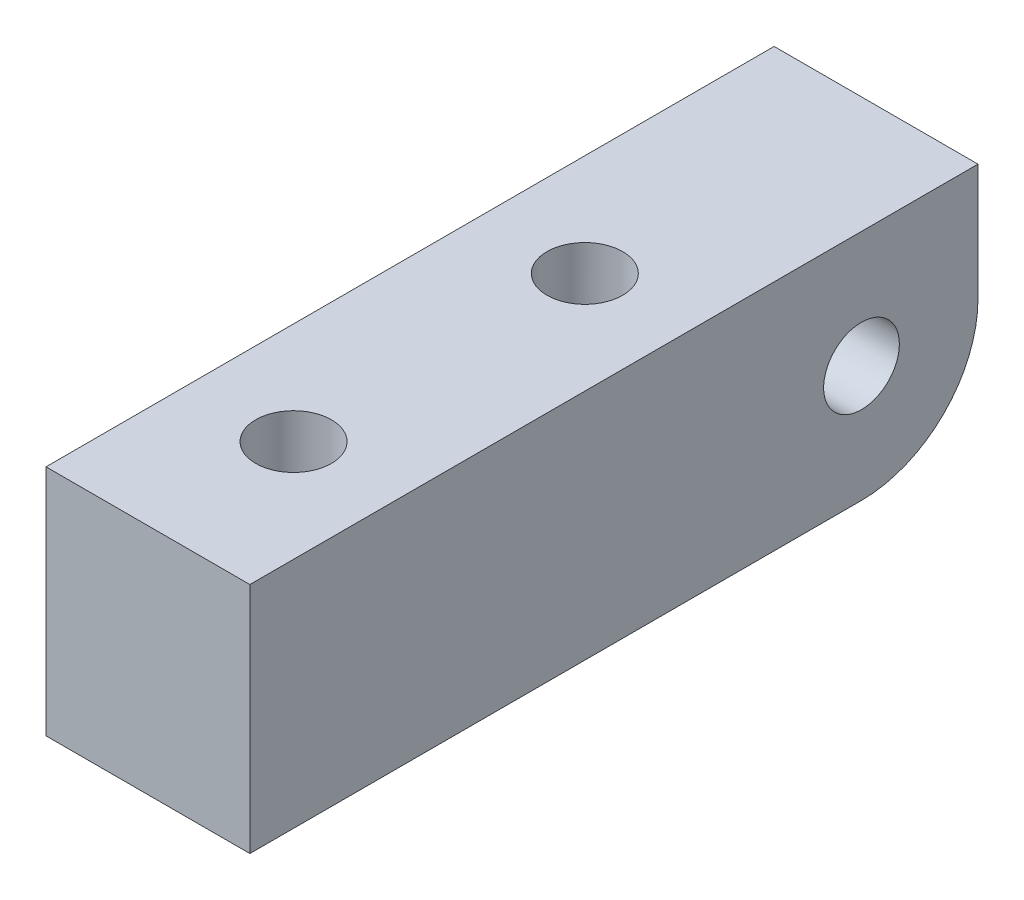
from build123d import *

# Parameters (mm, degrees)
SKETCH1_W           = 25
SKETCH1_H           = 8
SKETCH1_R           = 1.3
BOSS_EXTRUDE1_DEPTH = 3.5
FILLET1_R           = 4
SKETCH3_R           = 1.3
CUT_EXTRUDE6_DEPTH  = 9
SKETCH5_R           = 2.5
CUT_EXTRUDE7_DEPTH  = 3


with BuildPart() as part:
    # Sketch1 → Boss-Extrude1 (new body, symmetric)
    with BuildSketch(Plane(origin=(0, 0, 0), x_dir=(0, 0, -1), z_dir=(1, 0, 0))):
        with Locations((-8.5, 0)):
            Rectangle(SKETCH1_W, SKETCH1_H)
        Circle(SKETCH1_R, mode=Mode.SUBTRACT)
    extrude(amount=BOSS_EXTRUDE1_DEPTH, both=True)

    # Fillet1
    fillet1_edges = [part.edges().sort_by_distance(p)[0] for p in [
        (0, -4, -4),
    ]]
    fillet(fillet1_edges, radius=FILLET1_R)

    # Sketch3 → Cut-Extrude6 (cut, through all)
    with BuildSketch(Plane(origin=(0, 4, 0), x_dir=(1, 0, 0), z_dir=(0, 1, 0))):
        with Locations((0, -6)):
            Circle(SKETCH3_R)
        with Locations((0, -16)):
            Circle(SKETCH3_R)
    extrude(amount=-CUT_EXTRUDE6_DEPTH, mode=Mode.SUBTRACT)

    # Sketch5 → Cut-Extrude7 (cut)
    with BuildSketch(Plane.XZ.offset(4)):
        with Locations((0, 16)):
            Circle(SKETCH5_R)
        with Locations((0, 6)):
            Circle(SKETCH5_R)
    extrude(amount=-CUT_EXTRUDE7_DEPTH, mode=Mode.SUBTRACT)


solid = part.part
